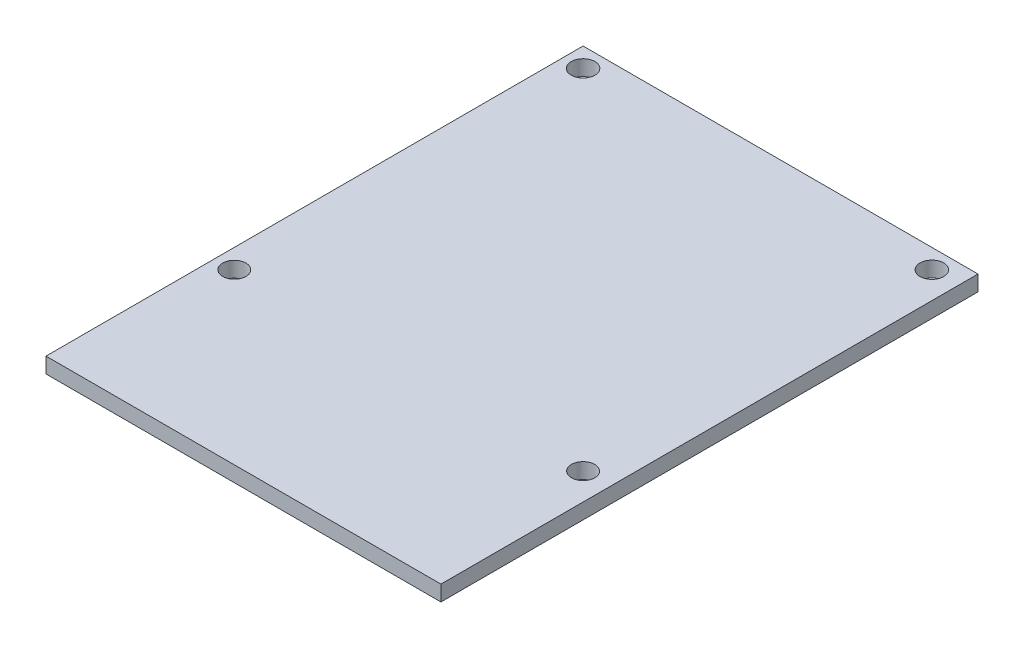
from build123d import *

# Parameters (mm, degrees)
SKETCH1_W           = 50.953125296
SKETCH1_H           = 69.296250402
SKETCH1_R           = 1.528593759
SKETCH1_R_2         = 1.5
BOSS_EXTRUDE1_DEPTH = 2


with BuildPart() as part:
    # Sketch1 → Boss-Extrude1 (new body)
    with BuildSketch(Plane(origin=(0, 0, 0), x_dir=(1, 0, 0), z_dir=(0, 1, 0))):
        Rectangle(SKETCH1_W, SKETCH1_H)
        with Locations((-22.976562648, 32.148125201)):
            Circle(SKETCH1_R, mode=Mode.SUBTRACT)
        with Locations((22.023437352, 32.148125201)):
            Circle(SKETCH1_R, mode=Mode.SUBTRACT)
        with Locations((-22.976562648, -12.851874799)):
            Circle(SKETCH1_R_2, mode=Mode.SUBTRACT)
        with Locations((22.023437352, -12.851874799)):
            Circle(SKETCH1_R_2, mode=Mode.SUBTRACT)
    extrude(amount=BOSS_EXTRUDE1_DEPTH)


solid = part.part
